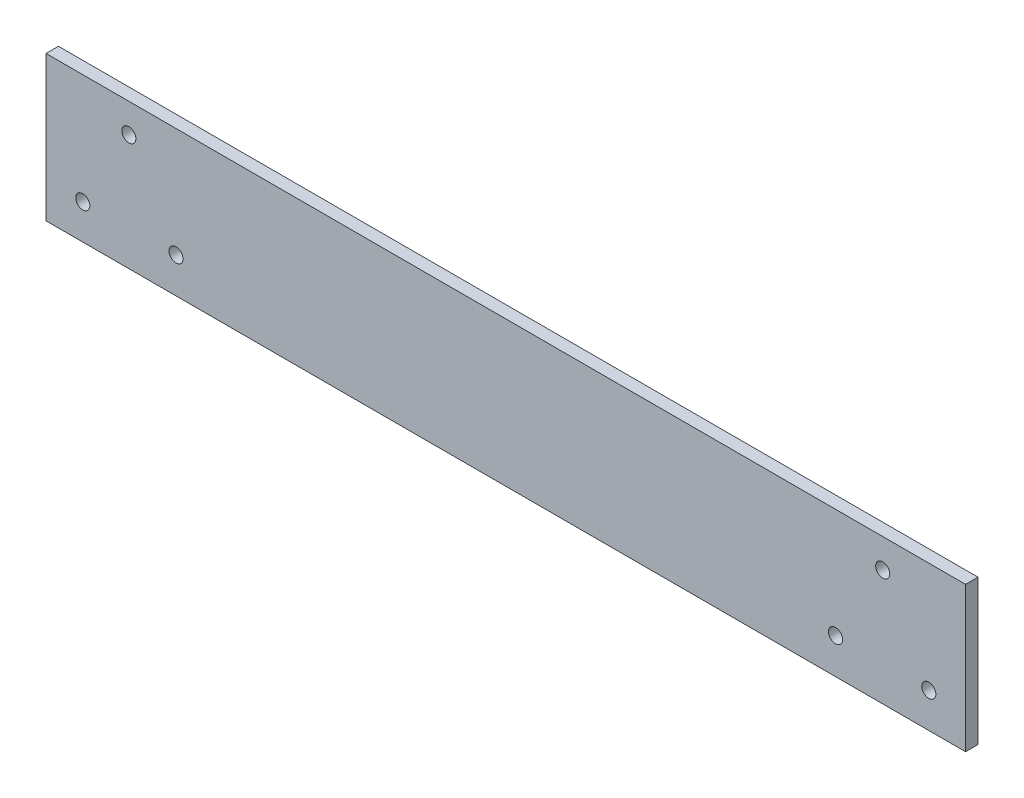
from build123d import *

# Parameters (mm, degrees)
ESQUISSE1_W        = 222
ESQUISSE1_H        = 35
ESQUISSE1_R        = 1.7
BOSS_EXTRU_1_DEPTH = 3


with BuildPart() as part:
    # Esquisse1 → Boss.-Extru.1 (new body)
    with BuildSketch(Plane.XY):
        with Locations((55.622910416, -6.804171429)):
            Rectangle(ESQUISSE1_W, ESQUISSE1_H)
        with Locations((-35.377089584, 3.695828571)):
            Circle(ESQUISSE1_R, mode=Mode.SUBTRACT)
        with Locations((-23.978402981, -15.72313665)):
            Circle(ESQUISSE1_R, mode=Mode.SUBTRACT)
        with Locations((-46.495063479, -15.885206207)):
            Circle(ESQUISSE1_R, mode=Mode.SUBTRACT)
        with Locations((135.224223814, -15.72313665)):
            Circle(ESQUISSE1_R, mode=Mode.SUBTRACT)
        with Locations((157.740884312, -15.885206207)):
            Circle(ESQUISSE1_R, mode=Mode.SUBTRACT)
        with Locations((146.622910416, 3.695828571)):
            Circle(ESQUISSE1_R, mode=Mode.SUBTRACT)
    extrude(amount=BOSS_EXTRU_1_DEPTH)


solid = part.part
